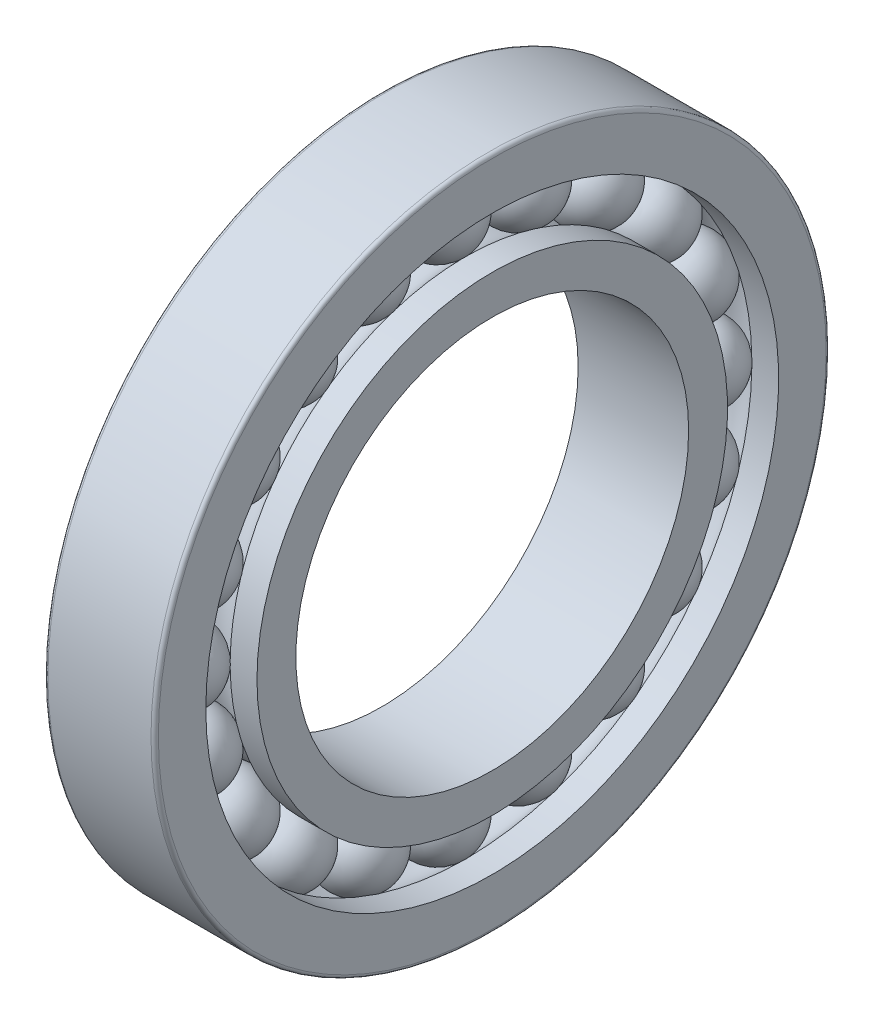
from build123d import *

# Parameters (mm, degrees)
CIRCULAR_PATTERN1_COUNT = 20
FILLET1_R               = 0.3
CUT_EXTRUDE1_REACH      = 11
SKETCH4_R               = 16


with BuildPart() as part:
    # Sketch1 → Revolve1 (revolve)
    with BuildSketch(Plane.XY):
        with BuildLine():
            Line((-3.125, 21.25), (3.125, 21.25))
            ThreePointArc((3.125, 21.25), (0, 24.375), (-3.125, 21.25))
        make_face()
    revolve1 = revolve(axis=Axis((-4.596601835, 21.25, 0), (1, 0, 0)))

    # Sketch2 → Revolve2 (revolve)
    with BuildSketch(Plane.XY):
        with BuildLine():
            Line((-4.5, 19.166666667), (-4.5, 15))
            Line((-4.5, 15), (4.5, 15))
            Line((4.5, 15), (4.5, 19.166666667))
            Line((4.5, 19.166666667), (2.315803796, 19.166666667))
            ThreePointArc((2.315803796, 19.166666667), (0, 18.135), (-2.315803796, 19.166666667))
            Line((-2.315803796, 19.166666667), (-4.5, 19.166666667))
        make_face()
    revolve(axis=Axis((-6.971390126, 0, 0), (1, 0, 0)))

    # Sketch3 → Revolve3 (revolve)
    with BuildSketch(Plane.XY):
        with BuildLine():
            Line((-4.5, 27.5), (4.5, 27.5))
            Line((4.5, 27.5), (4.5, 23.333333333))
            Line((4.5, 23.333333333), (2.315803796, 23.333333333))
            ThreePointArc((2.315803796, 23.333333333), (0, 24.365), (-2.315803796, 23.333333333))
            Line((-2.315803796, 23.333333333), (-4.5, 23.333333333))
            Line((-4.5, 23.333333333), (-4.5, 27.5))
        make_face()
    revolve(axis=Axis((-8.710676495, 0, 0), (1, 0, 0)))

    # Circular-Pattern1: Revolve1 ×20 about axis
    circular_pattern1_axis = Axis((0, 0, 0), (1, 0, 0))
    for i in range(1, CIRCULAR_PATTERN1_COUNT):
        add(revolve1.rotate(circular_pattern1_axis, i * 360 / CIRCULAR_PATTERN1_COUNT))

    # Fillet1
    fillet1_edges = [part.edges().sort_by_distance(p)[0] for p in [
        (-4.5, -27.5, 0),
        (4.5, -27.5, 0),
        (-4.5, -15, 0),
        (4.5, -15, 0),
    ]]
    fillet(fillet1_edges, radius=FILLET1_R)

    # Sketch4 → Cut-Extrude1 (cut, up to next)
    with BuildSketch(Plane(origin=(4.5, 0, 0), x_dir=(0, 0, -1), z_dir=(1, 0, 0)), mode=Mode.PRIVATE) as cut_extrude1_sk1:
        Circle(SKETCH4_R)
    cut_extrude1_tool1 = extrude(cut_extrude1_sk1.sketch, amount=-CUT_EXTRUDE1_REACH, mode=Mode.PRIVATE) & part.part
    add(cut_extrude1_tool1.solids().sort_by_distance((4.5, 0, 0))[0], mode=Mode.SUBTRACT)


solid = part.part
